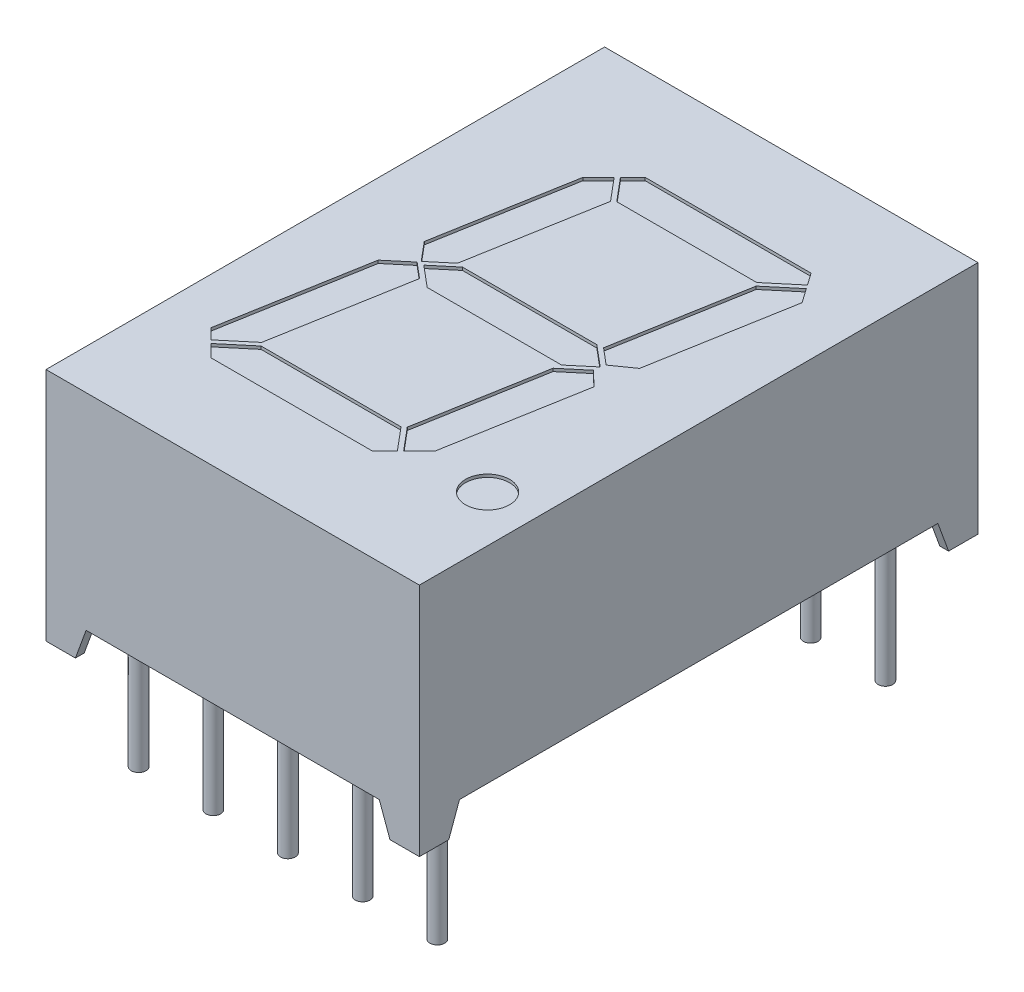
from build123d import *

# Parameters (mm, degrees)
SKETCH1_W          = 12.7
SKETCH1_H          = 19
EXTRUDE2_DEPTH     = 8
CUT_EXTRUDE2_DEPTH = 20
CUT_EXTRUDE3_DEPTH = 13.7
SKETCH6_R          = 0.75
CUT_EXTRUDE4_DEPTH = 0.1
SKETCH7_W          = 1.063970234
SKETCH7_H          = 1.063970234
CUT_EXTRUDE6_DEPTH = 1
SKETCH7_3_R        = 0.25
EXTRUDE3_DEPTH     = 1
SKETCH7_4_R        = 0.25
EXTRUDE4_DEPTH     = 4
SKETCH8_W          = 0.025316456
SKETCH8_H          = 0.026582279
SKETCH8_W_2        = 0.025316455
CUT_EXTRUDE7_DEPTH = 0.01


with BuildPart() as part:
    # Sketch1 → Extrude2 (new body)
    with BuildSketch(Plane(origin=(0, 0, 0), x_dir=(1, 0, 0), z_dir=(0, 1, 0))):
        Rectangle(SKETCH1_W, SKETCH1_H)
    extrude(amount=-EXTRUDE2_DEPTH)

    # Sketch2 → Cut-Extrude2 (cut, through all)
    with BuildSketch(Plane.XY.offset(9.5)):
        Polygon((-5.35, -8), (-4.986029766, -7), (4.986029766, -7), (5.35, -8), align=None)
    extrude(amount=-CUT_EXTRUDE2_DEPTH, mode=Mode.SUBTRACT)

    # Sketch3 → Cut-Extrude3 (cut, through all)
    with BuildSketch(Plane(origin=(6.35, 0, 0), x_dir=(0, 0, -1), z_dir=(1, 0, 0))):
        Polygon((-8.5, -8), (-8.136029766, -7), (8.136029766, -7), (8.5, -8), align=None)
    extrude(amount=-CUT_EXTRUDE3_DEPTH, mode=Mode.SUBTRACT)

    # Sketch6 → Cut-Extrude4 (cut)
    with BuildSketch(Plane(origin=(0, 0, 0), x_dir=(-1, 0, 0), z_dir=(0, 1, 0))):
        Polygon((2.347060671, -5.821729157), (2.87945, -5.289339828), (3.688046352, -0.703562037), (3.153743641, -0.066804861), (2.482496981, -0.630047685), (1.702508557, -5.053581859), align=None)
        Polygon((3.204420755, 0.024281714), (3.922651292, 0.626948692), (4.775927145, 5.466116524), (4.419664689, 5.822378979), (3.481414193, 5.035093334), (2.676048677, 0.467638529), align=None)
        Polygon((1.818789828, -6.35), (2.240589499, -5.928200329), (1.58760189, -5.15), (-3.173403674, -5.15), (-4.111654171, -5.937285646), (-3.822668469, -6.35), align=None)
        Polygon((2.284947844, -0.6), (3, 0), (2.284947844, 0.6), (-2.284947844, 0.6), (-3, 0), (-2.284947844, -0.6), align=None)
        Polygon((3.384996051, 5.15), (4.313193517, 5.928850151), (3.892043668, 6.35), (-1.607197451, 6.35), (-2.028997122, 5.928200329), (-1.376009513, 5.15), align=None)
        Polygon((-4.198019282, -5.813943485), (-3.269821816, -5.035093334), (-2.49172768, -0.622302209), (-3.045884018, -0.157309831), (-3.710853967, -0.625786375), (-4.539639014, -5.326059945), align=None)
        Polygon((-2.234161974, 0.838425499), (-1.49091618, 5.053581859), (-2.135468294, 5.821729157), (-2.667857623, 5.289339828), (-3.478951131, 0.689399965), (-2.980595373, 0.212093509), align=None)
        with Locations(Location((-4.768396343, 5.6, 0), (0, 0, 270))):  # turned: the seam where the file's is
            Circle(SKETCH6_R)
    extrude(amount=-CUT_EXTRUDE4_DEPTH, mode=Mode.SUBTRACT)

    # Sketch7 → Cut-Extrude6 (cut)
    with BuildSketch(Plane.XZ.offset(8)):
        with Locations((-5.518014883, 8.668014883)):
            Rectangle(SKETCH7_W, SKETCH7_H)
        with Locations((-5.518014883, -8.668014883)):
            Rectangle(SKETCH7_W, SKETCH7_H)
        with Locations((5.518014883, -8.668014883)):
            Rectangle(SKETCH7_W, SKETCH7_H)
        with Locations((5.518014883, 8.668014883)):
            Rectangle(SKETCH7_W, SKETCH7_H)
    extrude(amount=-CUT_EXTRUDE6_DEPTH, mode=Mode.SUBTRACT)

    # Sketch7_3 → Extrude3 (add)
    with BuildSketch(Plane.XZ.offset(8)):
        with Locations(Location((-5.08, 7.62, 0), (0, 0, 270))):  # turned: the seam where the file's is
            Circle(SKETCH7_3_R)
        with Locations(Location((-2.54, 7.62, 0), (0, 0, 270))):  # turned: the seam where the file's is
            Circle(SKETCH7_3_R)
        with Locations(Location((0, 7.62, 0), (0, 0, 270))):  # turned: the seam where the file's is
            Circle(SKETCH7_3_R)
        with Locations(Location((5.08, 7.62, 0), (0, 0, 270))):  # turned: the seam where the file's is
            Circle(SKETCH7_3_R)
        with Locations(Location((2.54, 7.62, 0), (0, 0, 270))):  # turned: the seam where the file's is
            Circle(SKETCH7_3_R)
        with Locations(Location((2.54, -7.62, 0), (0, 0, 270))):  # turned: the seam where the file's is
            Circle(SKETCH7_3_R)
        with Locations(Location((5.08, -7.62, 0), (0, 0, 270))):  # turned: the seam where the file's is
            Circle(SKETCH7_3_R)
        with Locations(Location((0, -7.62, 0), (0, 0, 270))):  # turned: the seam where the file's is
            Circle(SKETCH7_3_R)
        with Locations(Location((-2.54, -7.62, 0), (0, 0, 270))):  # turned: the seam where the file's is
            Circle(SKETCH7_3_R)
        with Locations(Location((-5.08, -7.62, 0), (0, 0, 270))):  # turned: the seam where the file's is
            Circle(SKETCH7_3_R)
    extrude(amount=-EXTRUDE3_DEPTH)

    # Sketch7_4 → Extrude4 (add)
    with BuildSketch(Plane.XZ.offset(8)):
        with Locations(Location((-5.08, 7.62, 0), (0, 0, 270))):  # turned: the seam where the file's is
            Circle(SKETCH7_4_R)
        with Locations(Location((-2.54, 7.62, 0), (0, 0, 270))):  # turned: the seam where the file's is
            Circle(SKETCH7_4_R)
        with Locations(Location((0, 7.62, 0), (0, 0, 270))):  # turned: the seam where the file's is
            Circle(SKETCH7_4_R)
        with Locations(Location((5.08, 7.62, 0), (0, 0, 270))):  # turned: the seam where the file's is
            Circle(SKETCH7_4_R)
        with Locations(Location((2.54, 7.62, 0), (0, 0, 270))):  # turned: the seam where the file's is
            Circle(SKETCH7_4_R)
        with Locations(Location((2.54, -7.62, 0), (0, 0, 270))):  # turned: the seam where the file's is
            Circle(SKETCH7_4_R)
        with Locations(Location((5.08, -7.62, 0), (0, 0, 270))):  # turned: the seam where the file's is
            Circle(SKETCH7_4_R)
        with Locations(Location((0, -7.62, 0), (0, 0, 270))):  # turned: the seam where the file's is
            Circle(SKETCH7_4_R)
        with Locations(Location((-2.54, -7.62, 0), (0, 0, 270))):  # turned: the seam where the file's is
            Circle(SKETCH7_4_R)
        with Locations(Location((-5.08, -7.62, 0), (0, 0, 270))):  # turned: the seam where the file's is
            Circle(SKETCH7_4_R)
    extrude(amount=EXTRUDE4_DEPTH)

    # Sketch8 → Cut-Extrude7 (cut)
    with BuildSketch(Plane.XZ.offset(7)):
        Polygon((0.95125277, 6.247515383), (0.974710048, 6.322198928), (0.999452928, 6.322198928), (1.015869067, 6.271862693), (1.031395175, 6.322198928), (1.057126979, 6.322198928), (1.080366694, 6.247515383), (1.055188688, 6.247515383), (1.042194226, 6.298998769), (1.025778086, 6.247515383), (1.004278878, 6.247515383), (0.987961631, 6.298998769), (0.975145175, 6.247515383), align=None)
        Polygon((0.817075555, 6.247515383), (0.840532833, 6.322198928), (0.865275713, 6.322198928), (0.881691852, 6.271862693), (0.89721796, 6.322198928), (0.922949764, 6.322198928), (0.946189479, 6.247515383), (0.921011472, 6.247515383), (0.90801701, 6.298998769), (0.891600871, 6.247515383), (0.870101662, 6.247515383), (0.853784416, 6.298998769), (0.84096796, 6.247515383), align=None)
        Polygon((0.68289834, 6.247515383), (0.706355618, 6.322198928), (0.731098498, 6.322198928), (0.747514637, 6.271862693), (0.763040745, 6.322198928), (0.788772548, 6.322198928), (0.812012264, 6.247515383), (0.786834257, 6.247515383), (0.773839795, 6.298998769), (0.757423656, 6.247515383), (0.735924447, 6.247515383), (0.7196072, 6.298998769), (0.706790745, 6.247515383), align=None)
        with Locations((0.655050238, 6.308907789)):
            Rectangle(SKETCH8_W, SKETCH8_H)
        with BuildLine():
            add(Edge.make_bspline(
                [(0.538594542, 6.291028041), (0.53863107, 6.292250156), (0.538702799, 6.29464998), (0.539311962, 6.298157946), (0.540307486, 6.301481229), (0.541671824, 6.304643945), (0.543485812, 6.307599311), (0.545640825, 6.310417878), (0.54825274, 6.313001839), (0.551189776, 6.315440601), (0.554487704, 6.317622995), (0.558090325, 6.319523134), (0.561960645, 6.321147852), (0.566114666, 6.322479542), (0.570560243, 6.323470309), (0.57527802, 6.324193627), (0.580271369, 6.324667134), (0.583694957, 6.324709076), (0.585449764, 6.324730573)],
                knots=[0, 0, 0, 0, 0.907421153, 1.781872267, 2.635683434, 3.480115191, 4.332689235, 5.205575272, 6.109500117, 7.055808355, 8.037942167, 9.041423561, 10.07750834, 11.152467461, 12.277657752, 13.45734338, 14.696726425, 16, 16, 16, 16], degree=3))
            add(Edge.make_bspline(
                [(0.585449764, 6.324730573), (0.587467748, 6.324703308), (0.591375934, 6.324650505), (0.597043503, 6.324265131), (0.602306969, 6.323577182), (0.607204716, 6.322620601), (0.611809017, 6.321417316), (0.616242361, 6.320126672), (0.620523653, 6.318662092), (0.623296745, 6.317561956), (0.624670491, 6.317016965)],
                knots=[0, 0, 0, 0, 1.203182053, 2.33017619, 3.384818652, 4.366208123, 5.30340534, 6.221361684, 7.118890722, 8, 8, 8, 8], degree=3))
            Line((0.624670491, 6.317016965), (0.624670491, 6.293085003))
            Line((0.624670491, 6.293085003), (0.62182239, 6.293085003))
            add(Edge.make_bspline(
                [(0.62182239, 6.293085003), (0.620456827, 6.294165966), (0.617733717, 6.296321545), (0.613306759, 6.2990899), (0.608647747, 6.30146291), (0.603809354, 6.303445533), (0.598907985, 6.305021147), (0.594038918, 6.306148052), (0.589269935, 6.306887417), (0.586111613, 6.306968978), (0.584559732, 6.307009054)],
                knots=[0, 0, 0, 0, 1.030738938, 2.055426519, 3.085610749, 4.123842265, 5.148648843, 6.130724483, 7.081507926, 8, 8, 8, 8], degree=3))
            add(Edge.make_bspline(
                [(0.584559732, 6.307009054), (0.584130986, 6.307007753), (0.583213073, 6.307004969), (0.581743926, 6.306883654), (0.580087582, 6.30675581), (0.578306844, 6.306559695), (0.576519639, 6.306328551), (0.574859391, 6.305982083), (0.57335863, 6.305612932), (0.57245196, 6.305245667), (0.572020175, 6.305070763)],
                knots=[0, 0, 0, 0, 0.806537132, 1.726733348, 2.77251655, 3.932999672, 5.098049949, 6.161349231, 7.124375527, 8, 8, 8, 8], degree=3))
            add(Edge.make_bspline(
                [(0.572020175, 6.305070763), (0.571540689, 6.304842527), (0.570598396, 6.304393996), (0.569295866, 6.303580086), (0.56812538, 6.302685341), (0.567064678, 6.301723608), (0.566202283, 6.30056062), (0.565581122, 6.299161349), (0.565236551, 6.297512056), (0.565197479, 6.296336894), (0.565176821, 6.295715541)],
                knots=[0, 0, 0, 0, 1.02474257, 2.013837243, 2.958431669, 3.867978675, 4.769292696, 5.732237074, 6.800947934, 8, 8, 8, 8], degree=3))
            add(Edge.make_bspline(
                [(0.565176821, 6.295715541), (0.565208282, 6.295169675), (0.565270144, 6.294096341), (0.56585165, 6.292567912), (0.566735697, 6.291147776), (0.568015113, 6.289882439), (0.569628791, 6.288756327), (0.571559778, 6.287745564), (0.573833629, 6.286909807), (0.575470842, 6.286471935), (0.576331884, 6.286241649)],
                knots=[0, 0, 0, 0, 0.825427492, 1.623033598, 2.45033906, 3.348940377, 4.33183287, 5.428402891, 6.647546779, 8, 8, 8, 8], degree=3))
            add(Edge.make_bspline(
                [(0.576331884, 6.286241649), (0.578301125, 6.285796444), (0.582336336, 6.284884166), (0.588476149, 6.283696712), (0.594614852, 6.282470841), (0.598571109, 6.281256527), (0.600501188, 6.280664117)],
                knots=[0, 0, 0, 0, 0.976118991, 2.000185432, 3.024380873, 4, 4, 4, 4], degree=3))
            add(Edge.make_bspline(
                [(0.600501188, 6.280664117), (0.60153934, 6.280310395), (0.603560202, 6.27962184), (0.606459394, 6.278469192), (0.609102642, 6.277164058), (0.611560181, 6.275842019), (0.613752845, 6.274361962), (0.615747479, 6.272829203), (0.61750014, 6.271176398), (0.619026577, 6.269426906), (0.620369443, 6.267590544), (0.621522853, 6.265643402), (0.622483876, 6.263576953), (0.623307267, 6.261421555), (0.623918494, 6.25914702), (0.62434093, 6.256770603), (0.624638993, 6.254287117), (0.624659849, 6.252592781), (0.624670491, 6.2517282)],
                knots=[0, 0, 0, 0, 1.287376879, 2.505999703, 3.65855109, 4.746193839, 5.778582289, 6.760029101, 7.696159662, 8.601061861, 9.48181646, 10.363080883, 11.252765705, 12.153987336, 13.068239035, 14.012364187, 14.985753787, 16, 16, 16, 16], degree=3))
            add(Edge.make_bspline(
                [(0.624670491, 6.2517282), (0.624633191, 6.250572053), (0.624559785, 6.248296778), (0.623958334, 6.244967756), (0.622931824, 6.241818937), (0.621545464, 6.238815781), (0.619717971, 6.236001518), (0.617525849, 6.233324032), (0.614915538, 6.230831535), (0.611930211, 6.228532899), (0.608643364, 6.226454093), (0.605109359, 6.224617386), (0.601330507, 6.223110938), (0.597350623, 6.221829707), (0.59313123, 6.220877312), (0.588694259, 6.220157734), (0.584020397, 6.219744734), (0.580828986, 6.219693458), (0.579199764, 6.219667282)],
                knots=[0, 0, 0, 0, 0.894901293, 1.761149761, 2.608783409, 3.453876344, 4.314933854, 5.200038827, 6.12799933, 7.103249695, 8.113098521, 9.136064399, 10.182719798, 11.259667356, 12.370545059, 13.528828137, 14.738461593, 16, 16, 16, 16], degree=3))
            add(Edge.make_bspline(
                [(0.579199764, 6.219667282), (0.577531112, 6.219689675), (0.574196638, 6.219734422), (0.569214665, 6.220109392), (0.564257251, 6.220675893), (0.559385687, 6.221475347), (0.554703179, 6.222493003), (0.550286566, 6.223578961), (0.546207595, 6.224819351), (0.54363387, 6.225773397), (0.54239201, 6.226233738)],
                knots=[0, 0, 0, 0, 1.065379838, 2.128953261, 3.188461447, 4.250817766, 5.279613205, 6.247547721, 7.154416075, 8, 8, 8, 8], degree=3))
            Line((0.54239201, 6.226233738), (0.54239201, 6.248781206))
            Line((0.54239201, 6.248781206), (0.545220333, 6.248781206))
            add(Edge.make_bspline(
                [(0.545220333, 6.248781206), (0.546293293, 6.247981002), (0.548487523, 6.246344564), (0.552146276, 6.244258588), (0.556110336, 6.242309074), (0.560375238, 6.24058728), (0.564847778, 6.23916668), (0.569425324, 6.238137635), (0.574052389, 6.237498512), (0.57715398, 6.23742538), (0.578705302, 6.237388801)],
                knots=[0, 0, 0, 0, 0.89224925, 1.824673196, 2.804309561, 3.838364047, 4.890042674, 5.931526337, 6.965412421, 8, 8, 8, 8], degree=3))
            add(Edge.make_bspline(
                [(0.578705302, 6.237388801), (0.579800601, 6.237413011), (0.581990347, 6.237461411), (0.585264754, 6.237810665), (0.588499546, 6.238482407), (0.590542444, 6.239296743), (0.591561314, 6.239702883)],
                knots=[0, 0, 0, 0, 0.998993879, 1.997209027, 3.00113285, 4, 4, 4, 4], degree=3))
            add(Edge.make_bspline(
                [(0.591561314, 6.239702883), (0.591994794, 6.239904366), (0.592861463, 6.240307197), (0.594068466, 6.241079523), (0.59517177, 6.242009241), (0.596172775, 6.243061635), (0.597020831, 6.244230969), (0.597658491, 6.245500729), (0.598019311, 6.246862707), (0.598065147, 6.247796876), (0.598088213, 6.248266965)],
                knots=[0, 0, 0, 0, 1.005454979, 2.010239304, 3.005296729, 4.036100111, 5.060531193, 6.034954812, 7.011155677, 8, 8, 8, 8], degree=3))
            add(Edge.make_bspline(
                [(0.598088213, 6.248266965), (0.598053419, 6.248904896), (0.59798693, 6.250123924), (0.597386932, 6.251837621), (0.596389263, 6.253300732), (0.595236165, 6.254293726), (0.594119185, 6.254992486), (0.593078668, 6.255497725), (0.591879217, 6.256011148), (0.590501768, 6.256500345), (0.588966633, 6.256994392), (0.587257711, 6.257469062), (0.585375104, 6.257918621), (0.584059213, 6.258204773), (0.583373023, 6.258353991)],
                knots=[0, 0, 0, 0, 1.174343879, 2.244064321, 3.303704314, 4.407076671, 5.02483983, 5.732197225, 6.53898402, 7.431906431, 8.428480183, 9.514816237, 10.704066255, 12, 12, 12, 12], degree=3))
            add(Edge.make_bspline(
                [(0.583373023, 6.258353991), (0.581540398, 6.258730711), (0.577939696, 6.259470883), (0.57253462, 6.26056518), (0.567041566, 6.261877697), (0.563371016, 6.263006909), (0.561458466, 6.263595288)],
                knots=[0, 0, 0, 0, 0.995788186, 1.956503735, 2.935230479, 4, 4, 4, 4], degree=3))
            add(Edge.make_bspline(
                [(0.561458466, 6.263595288), (0.56051191, 6.26391453), (0.558660292, 6.264539017), (0.556019694, 6.265625336), (0.553572521, 6.266799193), (0.551305887, 6.268041162), (0.549230521, 6.269383596), (0.547344231, 6.270808929), (0.545646274, 6.272313711), (0.544157526, 6.273929431), (0.542828768, 6.27563978), (0.541716425, 6.277490393), (0.540720839, 6.279433922), (0.539967684, 6.281527365), (0.539343175, 6.283725892), (0.538921432, 6.286057827), (0.538627069, 6.288502045), (0.538605505, 6.290176644), (0.538594542, 6.291028041)],
                knots=[0, 0, 0, 0, 1.237326419, 2.420410185, 3.534642089, 4.598489486, 5.620241961, 6.59385002, 7.525152549, 8.426792174, 9.312230456, 10.203151844, 11.098070343, 12.012931196, 12.954244379, 13.926618287, 14.945853925, 16, 16, 16, 16], degree=3))
        make_face()
        with BuildLine():
            Line((0.446189479, 6.322198928), (0.470240112, 6.322198928))
            Line((0.470240112, 6.322198928), (0.470240112, 6.314366649))
            add(Edge.make_bspline(
                [(0.470240112, 6.314366649), (0.471333306, 6.315175444), (0.473440967, 6.316734789), (0.476615526, 6.31881185), (0.479633826, 6.320596273), (0.482564178, 6.32211939), (0.485570455, 6.323331561), (0.48880859, 6.324149941), (0.492310185, 6.324652665), (0.494737255, 6.324704027), (0.495991694, 6.324730573)],
                knots=[0, 0, 0, 0, 1.150945962, 2.219006967, 3.209666795, 4.118194914, 5.012574058, 5.946577101, 6.93868214, 8, 8, 8, 8], degree=3))
            add(Edge.make_bspline(
                [(0.495991694, 6.324730573), (0.497007969, 6.324707625), (0.49898695, 6.324662939), (0.501865249, 6.324321218), (0.504567216, 6.323772809), (0.507096052, 6.323004403), (0.509445752, 6.322001372), (0.511589432, 6.320729737), (0.513592009, 6.319297024), (0.515373956, 6.317590658), (0.516989503, 6.315692739), (0.518372073, 6.31356033), (0.519549778, 6.311227391), (0.520490878, 6.308675541), (0.521245967, 6.305917236), (0.521769899, 6.302937989), (0.522090492, 6.299750861), (0.522122431, 6.297555731), (0.522138846, 6.296427567)],
                knots=[0, 0, 0, 0, 1.108959949, 2.159465255, 3.158589008, 4.114545495, 5.039534357, 5.93921201, 6.830099133, 7.720870013, 8.624681761, 9.544731627, 10.487599671, 11.471264588, 12.508152322, 13.604835107, 14.769030043, 16, 16, 16, 16], degree=3))
            Line((0.522138846, 6.296427567), (0.522138846, 6.247515383))
            Line((0.522138846, 6.247515383), (0.498088213, 6.247515383))
            Line((0.498088213, 6.247515383), (0.498088213, 6.285094497))
            add(Edge.make_bspline(
                [(0.498088213, 6.285094497), (0.498086577, 6.286010968), (0.498083447, 6.287765184), (0.498001108, 6.29027099), (0.497880207, 6.292539163), (0.497741503, 6.294581191), (0.497488486, 6.296427942), (0.497110777, 6.298094103), (0.496639951, 6.299613705), (0.496175633, 6.300520407), (0.495952137, 6.300956839)],
                knots=[0, 0, 0, 0, 1.361401701, 2.605856924, 3.723918663, 4.735739235, 5.645738665, 6.489217889, 7.27279937, 8, 8, 8, 8], degree=3))
            add(Edge.make_bspline(
                [(0.495952137, 6.300956839), (0.495722129, 6.301355545), (0.495269952, 6.302139366), (0.494349687, 6.303145677), (0.493270845, 6.303989427), (0.491993641, 6.304647528), (0.490504074, 6.305138031), (0.488783216, 6.305518603), (0.486791474, 6.30569048), (0.485384006, 6.305724971), (0.484638846, 6.305743231)],
                knots=[0, 0, 0, 0, 0.849004071, 1.669068917, 2.503060811, 3.370079215, 4.310762265, 5.396376419, 6.621555549, 8, 8, 8, 8], degree=3))
            add(Edge.make_bspline(
                [(0.484638846, 6.305743231), (0.484097903, 6.305723392), (0.482986487, 6.305682631), (0.481269034, 6.30549109), (0.479479774, 6.305091931), (0.476961106, 6.304446986), (0.473795896, 6.303253132), (0.471436362, 6.301899985), (0.470240112, 6.301213959)],
                knots=[0, 0, 0, 0, 0.638062719, 1.310959128, 2.033463623, 2.796942592, 4.376095945, 6, 6, 6, 6], degree=3))
            Line((0.470240112, 6.301213959), (0.470240112, 6.247515383))
            Line((0.470240112, 6.247515383), (0.446189479, 6.247515383))
            Line((0.446189479, 6.247515383), (0.446189479, 6.322198928))
        make_face()
        with BuildLine():
            Line((0.348721124, 6.322198928), (0.372771757, 6.322198928))
            Line((0.372771757, 6.322198928), (0.372771757, 6.284619814))
            add(Edge.make_bspline(
                [(0.372771757, 6.284619814), (0.372796764, 6.283089824), (0.372846735, 6.280032333), (0.373123286, 6.276269239), (0.373507773, 6.273427699), (0.373875313, 6.27159611), (0.374307184, 6.270047994), (0.374719445, 6.269162232), (0.374907833, 6.268757472)],
                knots=[0, 0, 0, 0, 1.709111167, 3.415443484, 4.21113913, 4.910175115, 5.501990373, 6, 6, 6, 6], degree=3))
            add(Edge.make_bspline(
                [(0.374907833, 6.268757472), (0.375152294, 6.268359409), (0.375631594, 6.267578951), (0.376568945, 6.266566074), (0.377662728, 6.265736706), (0.378933904, 6.265057239), (0.380422013, 6.264578051), (0.382145931, 6.264225297), (0.384126115, 6.264014743), (0.385534944, 6.263986189), (0.38628046, 6.263971079)],
                knots=[0, 0, 0, 0, 0.860202684, 1.686548532, 2.528236983, 3.382486038, 4.33249885, 5.401154041, 6.624757403, 8, 8, 8, 8], degree=3))
            add(Edge.make_bspline(
                [(0.38628046, 6.263971079), (0.387411349, 6.26403118), (0.389719045, 6.264153821), (0.392594354, 6.264820488), (0.394911693, 6.265680452), (0.396769409, 6.266430887), (0.398677131, 6.267404988), (0.399956673, 6.268126429), (0.400619859, 6.268500352)],
                knots=[0, 0, 0, 0, 1.33818541, 2.730705359, 3.468371228, 4.262126284, 5.099261778, 6, 6, 6, 6], degree=3))
            Line((0.400619859, 6.268500352), (0.400619859, 6.322198928))
            Line((0.400619859, 6.322198928), (0.424670491, 6.322198928))
            Line((0.424670491, 6.322198928), (0.424670491, 6.247515383))
            Line((0.424670491, 6.247515383), (0.400619859, 6.247515383))
            Line((0.400619859, 6.247515383), (0.400619859, 6.255347662))
            add(Edge.make_bspline(
                [(0.400619859, 6.255347662), (0.399562452, 6.25454151), (0.397504147, 6.252972288), (0.39432491, 6.250931867), (0.391241012, 6.249133098), (0.388188002, 6.247620282), (0.385073047, 6.246413507), (0.381810288, 6.245602518), (0.378393882, 6.245058715), (0.376057167, 6.245009021), (0.374868276, 6.244983738)],
                knots=[0, 0, 0, 0, 1.126119141, 2.192057864, 3.198061997, 4.149848529, 5.076251285, 6.021887753, 6.99356175, 8, 8, 8, 8], degree=3))
            add(Edge.make_bspline(
                [(0.374868276, 6.244983738), (0.373872011, 6.245009138), (0.371927125, 6.245058724), (0.369092275, 6.245368276), (0.366421169, 6.245919499), (0.363927785, 6.246715355), (0.361592098, 6.247706715), (0.359418426, 6.248910694), (0.357432577, 6.250373975), (0.355604425, 6.252033914), (0.353965325, 6.253925211), (0.352568416, 6.256054589), (0.351364054, 6.25839151), (0.350414788, 6.260954147), (0.349623464, 6.263720419), (0.349118701, 6.266719049), (0.348761048, 6.269928934), (0.348734698, 6.272145084), (0.348721124, 6.273286744)],
                knots=[0, 0, 0, 0, 1.08828964, 2.12453497, 3.110382522, 4.062402335, 4.978696626, 5.878225494, 6.769849763, 7.667011675, 8.57076823, 9.495541561, 10.442454184, 11.436213583, 12.475881554, 13.580560132, 14.753614518, 16, 16, 16, 16], degree=3))
            Line((0.348721124, 6.273286744), (0.348721124, 6.322198928))
        make_face()
        Polygon((0.253784416, 6.322198928), (0.325936314, 6.322198928), (0.325936314, 6.222198928), (0.300619859, 6.222198928), (0.300619859, 6.303211586), (0.253784416, 6.303211586), align=None)
        Polygon((0.166442643, 6.322198928), (0.238594542, 6.322198928), (0.238594542, 6.222198928), (0.166442643, 6.222198928), (0.166442643, 6.241186269), (0.213278086, 6.241186269), (0.213278086, 6.258907788), (0.170240112, 6.258907788), (0.170240112, 6.27789513), (0.213278086, 6.27789513), (0.213278086, 6.303211586), (0.166442643, 6.303211586), align=None)
        with BuildLine():
            add(Edge.make_bspline(
                [(0.049986947, 6.27229782), (0.050006262, 6.273445509), (0.050044515, 6.275718395), (0.050339706, 6.279083201), (0.050865731, 6.282348877), (0.051544913, 6.285533125), (0.052467418, 6.288612053), (0.053549132, 6.29161963), (0.054858778, 6.294525124), (0.056363631, 6.297326558), (0.058013103, 6.299998661), (0.059787852, 6.30251887), (0.061633631, 6.304902088), (0.063622944, 6.307096982), (0.065702125, 6.309139001), (0.067877654, 6.311029815), (0.070182718, 6.312733246), (0.071789881, 6.313756131), (0.072593751, 6.314267757)],
                knots=[0, 0, 0, 0, 1.105570398, 2.18947457, 3.250358341, 4.290584537, 5.323553275, 6.344225964, 7.367641686, 8.3905646, 9.405808457, 10.390761353, 11.358902336, 12.307789878, 13.241960776, 14.165076779, 15.082208636, 16, 16, 16, 16], degree=3))
            add(Edge.make_bspline(
                [(0.072593751, 6.314267757), (0.073832938, 6.314980078), (0.076317635, 6.316408355), (0.080302094, 6.318074194), (0.084423702, 6.319488417), (0.088782883, 6.320501857), (0.093421604, 6.321271692), (0.098426415, 6.321819864), (0.103833322, 6.322125366), (0.107568314, 6.322173848), (0.109500397, 6.322198928)],
                knots=[0, 0, 0, 0, 0.896321744, 1.797216976, 2.705381885, 3.628777036, 4.602292017, 5.655629376, 6.787275635, 8, 8, 8, 8], degree=3))
            Line((0.109500397, 6.322198928), (0.144923656, 6.322198928))
            Line((0.144923656, 6.322198928), (0.144923656, 6.222198928))
            Line((0.144923656, 6.222198928), (0.108491694, 6.222198928))
            add(Edge.make_bspline(
                [(0.108491694, 6.222198928), (0.106512998, 6.222215738), (0.102696339, 6.222248162), (0.097179022, 6.22266309), (0.092076684, 6.223268853), (0.087387104, 6.224163038), (0.083084654, 6.225277619), (0.079167363, 6.226666151), (0.075551129, 6.228158768), (0.073372594, 6.229433322), (0.072316852, 6.230050984)],
                knots=[0, 0, 0, 0, 1.267083275, 2.444046388, 3.541868212, 4.55639609, 5.499737919, 6.385160515, 7.217431253, 8, 8, 8, 8], degree=3))
            add(Edge.make_bspline(
                [(0.072316852, 6.230050984), (0.071465899, 6.230587525), (0.069773774, 6.231654439), (0.06737256, 6.233436291), (0.065143132, 6.235392368), (0.06301463, 6.237444187), (0.061034812, 6.239647073), (0.059191612, 6.241985781), (0.057487795, 6.244463875), (0.055929832, 6.247073344), (0.054509017, 6.249803396), (0.053319711, 6.252676455), (0.052270362, 6.255654985), (0.051464826, 6.258763947), (0.050766911, 6.261971783), (0.050332177, 6.265313127), (0.050045566, 6.268765616), (0.050006651, 6.271110505), (0.049986947, 6.27229782)],
                knots=[0, 0, 0, 0, 0.964065863, 1.917049184, 2.86229036, 3.805247319, 4.749389377, 5.698846072, 6.657678277, 7.629829384, 8.610569287, 9.604676042, 10.607940105, 11.6349849, 12.681042988, 13.752616828, 14.862056989, 16, 16, 16, 16], degree=3))
        make_face()
        with BuildLine():
            add(Edge.make_bspline(
                [(0.076569226, 6.272139592), (0.076612528, 6.270561162), (0.076696141, 6.267513362), (0.077401535, 6.263117718), (0.078540785, 6.259074768), (0.079878478, 6.255962352), (0.081215869, 6.253689035), (0.082343393, 6.252090764), (0.083593059, 6.250576565), (0.084983668, 6.249167725), (0.086518852, 6.247860689), (0.088180111, 6.246631778), (0.089980152, 6.245503132), (0.091253184, 6.244843126), (0.091897548, 6.244509054)],
                knots=[0, 0, 0, 0, 1.694683197, 3.272273219, 4.767406206, 6.197615014, 6.895990032, 7.597410435, 8.296503208, 9.002591366, 9.720792421, 10.460154445, 11.220583224, 12, 12, 12, 12], degree=3))
            add(Edge.make_bspline(
                [(0.091897548, 6.244509054), (0.092572483, 6.24420254), (0.093910252, 6.243595007), (0.095980527, 6.242860921), (0.098073229, 6.242298593), (0.100267456, 6.24182617), (0.102744216, 6.241549034), (0.105666707, 6.241336358), (0.10912338, 6.24119943), (0.111609976, 6.24119086), (0.112941852, 6.241186269)],
                knots=[0, 0, 0, 0, 0.826913061, 1.638999358, 2.447478739, 3.243919028, 4.140906711, 5.225381046, 6.513851968, 8, 8, 8, 8], degree=3))
            Line((0.112941852, 6.241186269), (0.1196072, 6.241186269))
            Line((0.1196072, 6.241186269), (0.1196072, 6.303211586))
            Line((0.1196072, 6.303211586), (0.112941852, 6.303211586))
            add(Edge.make_bspline(
                [(0.112941852, 6.303211586), (0.112183661, 6.30320654), (0.110719926, 6.303196799), (0.108603472, 6.303157696), (0.106638711, 6.30309738), (0.10483136, 6.303025537), (0.103175223, 6.302910634), (0.10168739, 6.302742037), (0.100345039, 6.30259765), (0.098777405, 6.30233053), (0.096924256, 6.301914075), (0.09476299, 6.301235984), (0.092622457, 6.300385564), (0.091233884, 6.2997006), (0.090532833, 6.299354782)],
                knots=[0, 0, 0, 0, 1.186775798, 2.291144404, 3.313233901, 4.263515562, 5.122260739, 5.910868134, 6.60717912, 7.234883681, 8.398964994, 9.577230746, 10.776813768, 12, 12, 12, 12], degree=3))
            add(Edge.make_bspline(
                [(0.090532833, 6.299354782), (0.089949119, 6.299011305), (0.088801182, 6.298335822), (0.087157038, 6.297229959), (0.085670298, 6.29599496), (0.084264237, 6.294711861), (0.08301137, 6.293321408), (0.081838077, 6.291870928), (0.080827821, 6.290308535), (0.079582826, 6.288115005), (0.078363094, 6.285081635), (0.077322334, 6.281115092), (0.076685819, 6.276755082), (0.076609086, 6.2737175), (0.076569226, 6.272139592)],
                knots=[0, 0, 0, 0, 0.755109416, 1.485004392, 2.205961541, 2.908125208, 3.605307969, 4.290649036, 4.985852759, 5.676964147, 7.100721462, 8.614478074, 10.241350405, 12, 12, 12, 12], degree=3))
        make_face(mode=Mode.SUBTRACT)
        with Locations((0.018341378, 6.308907789)):
            Rectangle(SKETCH8_W_2, SKETCH8_H)
        with BuildLine():
            add(Edge.make_bspline(
                [(-0.05630261, 6.324730573), (-0.054712504, 6.324708747), (-0.051591382, 6.324665905), (-0.047019937, 6.324189203), (-0.042655134, 6.323470736), (-0.038507516, 6.322452564), (-0.034600955, 6.321096222), (-0.030919901, 6.319478208), (-0.027530539, 6.317460402), (-0.025466809, 6.31588346), (-0.024439477, 6.315098453)],
                knots=[0, 0, 0, 0, 1.123606455, 2.205459211, 3.245124445, 4.248821949, 5.220056174, 6.165006393, 7.086533249, 8, 8, 8, 8], degree=3))
            add(Edge.make_bspline(
                [(-0.024439477, 6.315098453), (-0.023487729, 6.314243679), (-0.021587915, 6.312537436), (-0.019121982, 6.309566009), (-0.016998896, 6.306282965), (-0.015213343, 6.302680742), (-0.01378242, 6.298764014), (-0.012759286, 6.294519351), (-0.01214004, 6.289958571), (-0.012072875, 6.286810637), (-0.012038369, 6.28519339)],
                knots=[0, 0, 0, 0, 0.916457077, 1.82937027, 2.759194969, 3.714948755, 4.706655623, 5.743329475, 6.840637961, 8, 8, 8, 8], degree=3))
            add(Edge.make_bspline(
                [(-0.012038369, 6.28519339), (-0.01207713, 6.283490162), (-0.012152253, 6.280189082), (-0.012816012, 6.275416895), (-0.013885624, 6.270999214), (-0.015423183, 6.266947306), (-0.017353624, 6.263254114), (-0.019618117, 6.25988228), (-0.022238643, 6.256839355), (-0.024245781, 6.255093916), (-0.025250395, 6.254220288)],
                knots=[0, 0, 0, 0, 1.171797512, 2.271099083, 3.308930235, 4.294129479, 5.24602549, 6.17106565, 7.084581485, 8, 8, 8, 8], degree=3))
            add(Edge.make_bspline(
                [(-0.025250395, 6.254220288), (-0.026276308, 6.253451827), (-0.028340527, 6.251905622), (-0.031743371, 6.250003012), (-0.035371061, 6.248414818), (-0.039192796, 6.247138098), (-0.043167782, 6.246183481), (-0.047231336, 6.245490815), (-0.051375138, 6.245062133), (-0.054165518, 6.245009995), (-0.055570806, 6.244983738)],
                knots=[0, 0, 0, 0, 0.952046378, 1.915591786, 2.889970712, 3.892742799, 4.906722985, 5.925995921, 6.955492795, 8, 8, 8, 8], degree=3))
            add(Edge.make_bspline(
                [(-0.055570806, 6.244983738), (-0.05681761, 6.245000135), (-0.05926925, 6.245032378), (-0.062868091, 6.245362981), (-0.066326049, 6.245864919), (-0.069632968, 6.246603491), (-0.072799964, 6.247525108), (-0.075854104, 6.24855717), (-0.078813336, 6.249692402), (-0.080713981, 6.250576679), (-0.081658622, 6.251016174)],
                knots=[0, 0, 0, 0, 1.107549047, 2.177816721, 3.208424937, 4.210433793, 5.185680559, 6.13785309, 7.074491882, 8, 8, 8, 8], degree=3))
            Line((-0.081658622, 6.251016174), (-0.081658622, 6.271566016))
            Line((-0.081658622, 6.271566016), (-0.078316059, 6.271566016))
            add(Edge.make_bspline(
                [(-0.078316059, 6.271566016), (-0.077815481, 6.27115013), (-0.076730457, 6.270248677), (-0.074963625, 6.26880209), (-0.072793305, 6.2673018), (-0.071146276, 6.266407175), (-0.070266217, 6.265929149)],
                knots=[0, 0, 0, 0, 0.792743043, 1.718305972, 2.780820752, 4, 4, 4, 4], degree=3))
            add(Edge.make_bspline(
                [(-0.070266217, 6.265929149), (-0.069337282, 6.265490511), (-0.067431373, 6.26459055), (-0.064888165, 6.263713162), (-0.062684986, 6.263187794), (-0.060871326, 6.262922228), (-0.058937029, 6.26273537), (-0.057601883, 6.262715479), (-0.056915743, 6.262705257)],
                knots=[0, 0, 0, 0, 1.332360773, 2.733622135, 3.480580446, 4.268165618, 5.10999921, 6, 6, 6, 6], degree=3))
            add(Edge.make_bspline(
                [(-0.056915743, 6.262705257), (-0.056150104, 6.262724587), (-0.054666331, 6.26276205), (-0.052505964, 6.263042097), (-0.050481346, 6.26351019), (-0.048593308, 6.264188134), (-0.046839477, 6.2650399), (-0.045219453, 6.266081345), (-0.043726021, 6.267304617), (-0.04240708, 6.268746249), (-0.041214266, 6.270325989), (-0.040195088, 6.272060156), (-0.039282626, 6.273906741), (-0.038587689, 6.275911194), (-0.038027951, 6.278039968), (-0.037639021, 6.280303089), (-0.037397062, 6.282702599), (-0.037369145, 6.284348907), (-0.037354825, 6.28519339)],
                knots=[0, 0, 0, 0, 1.087372478, 2.107277257, 3.088614887, 4.033572876, 4.950837204, 5.852283781, 6.763600506, 7.684681617, 8.621202104, 9.570420019, 10.537986648, 11.542161979, 12.577980734, 13.661919757, 14.800668594, 16, 16, 16, 16], degree=3))
            add(Edge.make_bspline(
                [(-0.037354825, 6.28519339), (-0.037369599, 6.286057546), (-0.037398305, 6.287736558), (-0.03763182, 6.290178169), (-0.038047711, 6.292459601), (-0.038618959, 6.294584921), (-0.039343307, 6.296550939), (-0.040248424, 6.298348335), (-0.04128478, 6.300005143), (-0.042529338, 6.301467755), (-0.043893222, 6.302784076), (-0.045408114, 6.303920211), (-0.047067353, 6.304868356), (-0.048849533, 6.305672819), (-0.050782574, 6.306251217), (-0.052839111, 6.306687909), (-0.055028666, 6.306976465), (-0.05653902, 6.306998028), (-0.057311312, 6.307009054)],
                knots=[0, 0, 0, 0, 1.230336593, 2.390482092, 3.487897344, 4.52859895, 5.520747884, 6.465347575, 7.38981449, 8.296085817, 9.192433006, 10.084246191, 10.984321635, 11.908883871, 12.862027947, 13.850751296, 14.901019963, 16, 16, 16, 16], degree=3))
            add(Edge.make_bspline(
                [(-0.057311312, 6.307009054), (-0.058037077, 6.307000304), (-0.059451929, 6.306983247), (-0.061518929, 6.306773693), (-0.063476434, 6.306466922), (-0.065309576, 6.306026968), (-0.067012308, 6.305514418), (-0.068568642, 6.304941473), (-0.069981618, 6.304338346), (-0.070842908, 6.303870591), (-0.071255141, 6.303646712)],
                knots=[0, 0, 0, 0, 1.201052708, 2.34140671, 3.435973211, 4.479046096, 5.459661032, 6.378175262, 7.223757638, 8, 8, 8, 8], degree=3))
            add(Edge.make_bspline(
                [(-0.071255141, 6.303646712), (-0.071955347, 6.303216818), (-0.073309914, 6.302385176), (-0.075148642, 6.30098361), (-0.076793511, 6.29956935), (-0.077818022, 6.298613132), (-0.078316059, 6.298148295)],
                knots=[0, 0, 0, 0, 1.098601379, 2.125273733, 3.088655601, 4, 4, 4, 4], degree=3))
            Line((-0.078316059, 6.298148295), (-0.081658622, 6.298148295))
            Line((-0.081658622, 6.298148295), (-0.081658622, 6.318856364))
            add(Edge.make_bspline(
                [(-0.081658622, 6.318856364), (-0.080713233, 6.319293858), (-0.078822225, 6.320168952), (-0.075907646, 6.321322824), (-0.072919673, 6.322290984), (-0.069871301, 6.323194065), (-0.066699217, 6.323882427), (-0.063376187, 6.32437555), (-0.059894688, 6.324676462), (-0.057516299, 6.32471229), (-0.05630261, 6.324730573)],
                knots=[0, 0, 0, 0, 0.952012952, 1.904254716, 2.862729541, 3.822037426, 4.808956931, 5.82647221, 6.890850784, 8, 8, 8, 8], degree=3))
        make_face()
        with BuildLine():
            add(Edge.make_bspline(
                [(-0.174063686, 6.284896712), (-0.17403899, 6.286401618), (-0.173990852, 6.289335084), (-0.173451535, 6.293606875), (-0.172638756, 6.297642873), (-0.171466224, 6.301430082), (-0.169985832, 6.304987356), (-0.168134893, 6.308277149), (-0.165963888, 6.311330378), (-0.163472851, 6.314120263), (-0.160671649, 6.316618774), (-0.157597467, 6.318814027), (-0.15422364, 6.320627468), (-0.150609329, 6.322139559), (-0.146724677, 6.323308794), (-0.142570458, 6.324121511), (-0.138153323, 6.324656982), (-0.135114905, 6.324705633), (-0.133557357, 6.324730573)],
                knots=[0, 0, 0, 0, 1.120167703, 2.183507516, 3.201345984, 4.182878364, 5.131270247, 6.065524964, 6.98789854, 7.91635504, 8.84481154, 9.778033504, 10.722808862, 11.691211189, 12.691525459, 13.738229926, 14.840575679, 16, 16, 16, 16], degree=3))
            add(Edge.make_bspline(
                [(-0.133557357, 6.324730573), (-0.131999835, 6.324705551), (-0.12896147, 6.324656739), (-0.12454396, 6.324122407), (-0.120384866, 6.323304457), (-0.116495559, 6.322148356), (-0.112886813, 6.320621806), (-0.109516946, 6.318814758), (-0.106443181, 6.316618565), (-0.103641695, 6.314120373), (-0.101151376, 6.311330147), (-0.098977786, 6.308277964), (-0.097135372, 6.30498201), (-0.095617518, 6.301438964), (-0.094484193, 6.297638127), (-0.093660731, 6.293607685), (-0.093124523, 6.289334865), (-0.093075947, 6.286401544), (-0.093051028, 6.284896712)],
                knots=[0, 0, 0, 0, 1.15937715, 2.261678054, 3.308339936, 4.313313916, 5.277148057, 6.221884977, 7.155068972, 8.083487698, 9.011906424, 9.934242473, 10.868459181, 11.818729666, 12.798784262, 13.81658132, 14.879877871, 16, 16, 16, 16], degree=3))
            add(Edge.make_bspline(
                [(-0.093051028, 6.284896712), (-0.093076129, 6.28338528), (-0.093125173, 6.280432251), (-0.09366084, 6.276133504), (-0.094477802, 6.272072408), (-0.095643334, 6.268259857), (-0.097149611, 6.264697382), (-0.098996557, 6.261391193), (-0.101192311, 6.258344419), (-0.103701747, 6.255554254), (-0.106514512, 6.253059726), (-0.109602011, 6.250881622), (-0.11296555, 6.249072828), (-0.116565903, 6.247545063), (-0.120453564, 6.246412518), (-0.124590191, 6.245594362), (-0.128987674, 6.245056452), (-0.1320064, 6.245008417), (-0.133557357, 6.244983738)],
                knots=[0, 0, 0, 0, 1.123883205, 2.195836198, 3.217400301, 4.202580581, 5.156396106, 6.089661422, 7.013912723, 7.944661364, 8.875797629, 9.805201257, 10.748976071, 11.711828658, 12.709674189, 13.755270167, 14.846705509, 16, 16, 16, 16], degree=3))
            add(Edge.make_bspline(
                [(-0.133557357, 6.244983738), (-0.135128094, 6.24500846), (-0.138186259, 6.245056592), (-0.14262967, 6.245592795), (-0.14680351, 6.2464058), (-0.150702135, 6.247572196), (-0.154327885, 6.24908361), (-0.15768796, 6.250918268), (-0.160759268, 6.253120326), (-0.163546521, 6.255627482), (-0.166026763, 6.258432883), (-0.168195679, 6.261482507), (-0.170002896, 6.264802223), (-0.171484667, 6.268357091), (-0.17265684, 6.27215086), (-0.173477825, 6.276184966), (-0.173983816, 6.280459963), (-0.1740366, 6.283392093), (-0.174063686, 6.284896712)],
                knots=[0, 0, 0, 0, 1.167358552, 2.272800965, 3.322628764, 4.326027541, 5.29287265, 6.238482395, 7.166210353, 8.096447471, 9.020151799, 9.945039072, 10.873038967, 11.824425184, 12.804379233, 13.820580988, 14.881633558, 16, 16, 16, 16], degree=3))
        make_face()
        with BuildLine():
            add(Edge.make_bspline(
                [(-0.144356407, 6.303389592), (-0.14471141, 6.302889511), (-0.145433884, 6.301871786), (-0.146309692, 6.300167133), (-0.14708827, 6.29833468), (-0.147708743, 6.296307053), (-0.148192588, 6.294011939), (-0.148501042, 6.291364384), (-0.148731385, 6.288328992), (-0.148741741, 6.28617626), (-0.14874723, 6.285035162)],
                knots=[0, 0, 0, 0, 0.765001119, 1.556867793, 2.387180485, 3.249178546, 4.200309879, 5.312433676, 6.575401142, 8, 8, 8, 8], degree=3))
            add(Edge.make_bspline(
                [(-0.14874723, 6.285035162), (-0.148729496, 6.283960288), (-0.14869552, 6.281900946), (-0.148509737, 6.278941082), (-0.148158276, 6.276251584), (-0.14766476, 6.273826876), (-0.14705717, 6.271654806), (-0.146322368, 6.269722477), (-0.14548893, 6.268008523), (-0.144803176, 6.267003401), (-0.144475078, 6.266522503)],
                knots=[0, 0, 0, 0, 1.337015307, 2.56157572, 3.686511827, 4.707709802, 5.636963675, 6.488272502, 7.276717686, 8, 8, 8, 8], degree=3))
            add(Edge.make_bspline(
                [(-0.144475078, 6.266522503), (-0.144137691, 6.266083413), (-0.143475825, 6.265222034), (-0.142301036, 6.264137145), (-0.141029515, 6.263246884), (-0.139665054, 6.262550901), (-0.138204865, 6.262069181), (-0.136702504, 6.261712692), (-0.135146322, 6.261487289), (-0.134092126, 6.26145554), (-0.133557357, 6.261439434)],
                knots=[0, 0, 0, 0, 1.058488312, 2.076474566, 3.046302828, 4.022760093, 4.996603884, 5.982315336, 6.976474174, 8, 8, 8, 8], degree=3))
            add(Edge.make_bspline(
                [(-0.133557357, 6.261439434), (-0.133029425, 6.26145038), (-0.131996807, 6.261471791), (-0.130494142, 6.261651473), (-0.129083194, 6.261946063), (-0.12774332, 6.262363995), (-0.126451345, 6.262959478), (-0.125217001, 6.263815903), (-0.124001064, 6.264891234), (-0.123262817, 6.265741752), (-0.122876977, 6.266186269)],
                knots=[0, 0, 0, 0, 1.041978199, 2.038073998, 2.982578265, 3.884042198, 4.804014415, 5.778706634, 6.839057036, 8, 8, 8, 8], degree=3))
            add(Edge.make_bspline(
                [(-0.122876977, 6.266186269), (-0.122543492, 6.266660895), (-0.121841848, 6.267659496), (-0.120958873, 6.269364016), (-0.120227519, 6.271325936), (-0.119535279, 6.273509677), (-0.119017015, 6.275980826), (-0.118616276, 6.278734104), (-0.118415562, 6.281788531), (-0.118383986, 6.283920748), (-0.118367483, 6.285035162)],
                knots=[0, 0, 0, 0, 0.706185926, 1.485796665, 2.33004681, 3.254820698, 4.274138656, 5.402098861, 6.642194297, 8, 8, 8, 8], degree=3))
            add(Edge.make_bspline(
                [(-0.118367483, 6.285035162), (-0.118376639, 6.286037621), (-0.118394368, 6.287978726), (-0.118593154, 6.290785163), (-0.118922271, 6.293388918), (-0.119397432, 6.295779548), (-0.119978185, 6.297968433), (-0.120710275, 6.299926639), (-0.121549762, 6.301674358), (-0.122244969, 6.302698039), (-0.1225803, 6.303191807)],
                knots=[0, 0, 0, 0, 1.27086383, 2.460826804, 3.565079772, 4.596261907, 5.549370831, 6.432852304, 7.244093885, 8, 8, 8, 8], degree=3))
            add(Edge.make_bspline(
                [(-0.1225803, 6.303191807), (-0.12292079, 6.303608422), (-0.123592087, 6.304429805), (-0.124742019, 6.305511963), (-0.126019452, 6.306378457), (-0.12738153, 6.307082606), (-0.128840264, 6.307610279), (-0.130386705, 6.308017522), (-0.132041972, 6.308225103), (-0.133174494, 6.308258007), (-0.133755141, 6.308274877)],
                knots=[0, 0, 0, 0, 1.011466313, 1.994169768, 2.957274081, 3.905656451, 4.870834188, 5.869371193, 6.907620549, 8, 8, 8, 8], degree=3))
            add(Edge.make_bspline(
                [(-0.133755141, 6.308274877), (-0.13475655, 6.308223228), (-0.136756686, 6.308120068), (-0.139167836, 6.30738326), (-0.140969526, 6.306531204), (-0.142221516, 6.305676744), (-0.143370454, 6.304633312), (-0.144024542, 6.30380822), (-0.144356407, 6.303389592)],
                knots=[0, 0, 0, 0, 1.484683483, 2.96539121, 3.705388955, 4.438554905, 5.207767564, 6, 6, 6, 6], degree=3))
        make_face(mode=Mode.SUBTRACT)
        with BuildLine():
            Line((-0.265202926, 6.268500352), (-0.265202926, 6.322198928))
            Line((-0.265202926, 6.322198928), (-0.241152293, 6.322198928))
            Line((-0.241152293, 6.322198928), (-0.241152293, 6.284342915))
            add(Edge.make_bspline(
                [(-0.241152293, 6.284342915), (-0.241146827, 6.28345288), (-0.241136339, 6.281745249), (-0.241103315, 6.279285635), (-0.241023044, 6.277037031), (-0.240915505, 6.274990832), (-0.24072856, 6.273131367), (-0.24041722, 6.271456531), (-0.239995724, 6.269951006), (-0.239587373, 6.269050058), (-0.239392009, 6.268619022)],
                knots=[0, 0, 0, 0, 1.339742217, 2.570446543, 3.702449567, 4.726327994, 5.654556215, 6.512888379, 7.288529137, 8, 8, 8, 8], degree=3))
            add(Edge.make_bspline(
                [(-0.239392009, 6.268619022), (-0.239182001, 6.268233812), (-0.238765715, 6.26747023), (-0.237898859, 6.26650008), (-0.236883543, 6.265696045), (-0.235719866, 6.265020474), (-0.234324847, 6.264560428), (-0.232716848, 6.264199283), (-0.230851417, 6.264022798), (-0.229529367, 6.263988968), (-0.2288303, 6.263971079)],
                knots=[0, 0, 0, 0, 0.859137151, 1.703023591, 2.531884144, 3.395689496, 4.329139829, 5.403231912, 6.626892925, 8, 8, 8, 8], degree=3))
            add(Edge.make_bspline(
                [(-0.2288303, 6.263971079), (-0.228242861, 6.263994106), (-0.227062685, 6.264040367), (-0.22530812, 6.264289769), (-0.223582184, 6.264760001), (-0.221363883, 6.265604338), (-0.218762158, 6.26684163), (-0.216785778, 6.267961898), (-0.215835838, 6.268500352)],
                knots=[0, 0, 0, 0, 0.759272211, 1.52539342, 2.28366165, 3.065252147, 4.589423829, 6, 6, 6, 6], degree=3))
            Line((-0.215835838, 6.268500352), (-0.215835838, 6.322198928))
            Line((-0.215835838, 6.322198928), (-0.191785205, 6.322198928))
            Line((-0.191785205, 6.322198928), (-0.191785205, 6.247515383))
            Line((-0.191785205, 6.247515383), (-0.215835838, 6.247515383))
            Line((-0.215835838, 6.247515383), (-0.215835838, 6.255347662))
            add(Edge.make_bspline(
                [(-0.215835838, 6.255347662), (-0.216856577, 6.254565699), (-0.218838438, 6.253047445), (-0.221859302, 6.251006175), (-0.224803577, 6.249218235), (-0.227705745, 6.24768509), (-0.230661093, 6.246458694), (-0.233750193, 6.245615184), (-0.236993752, 6.245084886), (-0.239211922, 6.245017864), (-0.240341376, 6.244983738)],
                knots=[0, 0, 0, 0, 1.13602934, 2.205708752, 3.219814904, 4.178719654, 5.103700513, 6.040802208, 7.002410817, 8, 8, 8, 8], degree=3))
            add(Edge.make_bspline(
                [(-0.240341376, 6.244983738), (-0.241544524, 6.245015661), (-0.243895995, 6.245078053), (-0.24730924, 6.245744819), (-0.250517515, 6.246757656), (-0.253492081, 6.248214702), (-0.256195263, 6.250078676), (-0.258594381, 6.252350541), (-0.260707443, 6.254998643), (-0.261797777, 6.257009959), (-0.262354825, 6.258037535)],
                knots=[0, 0, 0, 0, 1.06596181, 2.083348439, 3.072786094, 4.043114605, 5.009947443, 5.973893017, 6.964867644, 8, 8, 8, 8], degree=3))
            add(Edge.make_bspline(
                [(-0.262354825, 6.258037535), (-0.263536911, 6.257060576), (-0.26584057, 6.25515667), (-0.269394164, 6.252613975), (-0.272873321, 6.250359674), (-0.276313572, 6.248449961), (-0.279709224, 6.246905073), (-0.283088351, 6.245799473), (-0.286437132, 6.245116026), (-0.288670391, 6.245027325), (-0.2897678, 6.244983738)],
                knots=[0, 0, 0, 0, 1.188124574, 2.315425566, 3.384037189, 4.39937427, 5.362203716, 6.270239573, 7.150007311, 8, 8, 8, 8], degree=3))
            add(Edge.make_bspline(
                [(-0.2897678, 6.244983738), (-0.290751051, 6.245007123), (-0.292664197, 6.245052626), (-0.295446733, 6.245387769), (-0.298042989, 6.245959047), (-0.300466715, 6.246751413), (-0.302702655, 6.247780128), (-0.304765784, 6.249027307), (-0.306613867, 6.250537806), (-0.308306651, 6.252236496), (-0.309795796, 6.254173165), (-0.311080433, 6.256311213), (-0.312151305, 6.258657999), (-0.313040647, 6.261192696), (-0.313728793, 6.263934101), (-0.31421813, 6.266877254), (-0.314516551, 6.270017116), (-0.314551893, 6.272178474), (-0.314570015, 6.273286744)],
                knots=[0, 0, 0, 0, 1.099136554, 2.138625863, 3.127574945, 4.066908717, 4.983764051, 5.873707737, 6.754323387, 7.645578618, 8.549333854, 9.478432518, 10.428234329, 11.428300305, 12.477672891, 13.584002437, 14.761160362, 16, 16, 16, 16], degree=3))
            Line((-0.314570015, 6.273286744), (-0.314570015, 6.322198928))
            Line((-0.314570015, 6.322198928), (-0.290519382, 6.322198928))
            Line((-0.290519382, 6.322198928), (-0.290519382, 6.284342915))
            add(Edge.make_bspline(
                [(-0.290519382, 6.284342915), (-0.290513709, 6.283446297), (-0.29050282, 6.281725497), (-0.290472572, 6.27925258), (-0.290384025, 6.276998104), (-0.290302305, 6.274951752), (-0.290136421, 6.273105716), (-0.289844454, 6.271441569), (-0.289417272, 6.269955634), (-0.289025242, 6.269050734), (-0.288838211, 6.268619022)],
                knots=[0, 0, 0, 0, 1.350818449, 2.592504867, 3.725474742, 4.749698069, 5.67770978, 6.515438232, 7.29174147, 8, 8, 8, 8], degree=3))
            add(Edge.make_bspline(
                [(-0.288838211, 6.268619022), (-0.288634756, 6.268234169), (-0.288231943, 6.267472214), (-0.287383969, 6.266495008), (-0.286365285, 6.26569095), (-0.285184571, 6.26502139), (-0.283764893, 6.264557353), (-0.282135623, 6.264203948), (-0.280245141, 6.264020392), (-0.278909729, 6.263988233), (-0.278197388, 6.263971079)],
                knots=[0, 0, 0, 0, 0.846272708, 1.675499002, 2.498229298, 3.366836971, 4.305509618, 5.396757786, 6.611368595, 8, 8, 8, 8], degree=3))
            add(Edge.make_bspline(
                [(-0.278197388, 6.263971079), (-0.277196269, 6.264018009), (-0.27518246, 6.264112411), (-0.272700958, 6.264833117), (-0.270672265, 6.265639653), (-0.268988662, 6.266452871), (-0.267129944, 6.267386807), (-0.265865113, 6.268117701), (-0.265202926, 6.268500352)],
                knots=[0, 0, 0, 0, 1.291206289, 2.597335145, 3.312416795, 4.112753053, 5.011956018, 6, 6, 6, 6], degree=3))
        make_face()
    extrude(amount=-CUT_EXTRUDE7_DEPTH, mode=Mode.SUBTRACT)


solid = part.part
